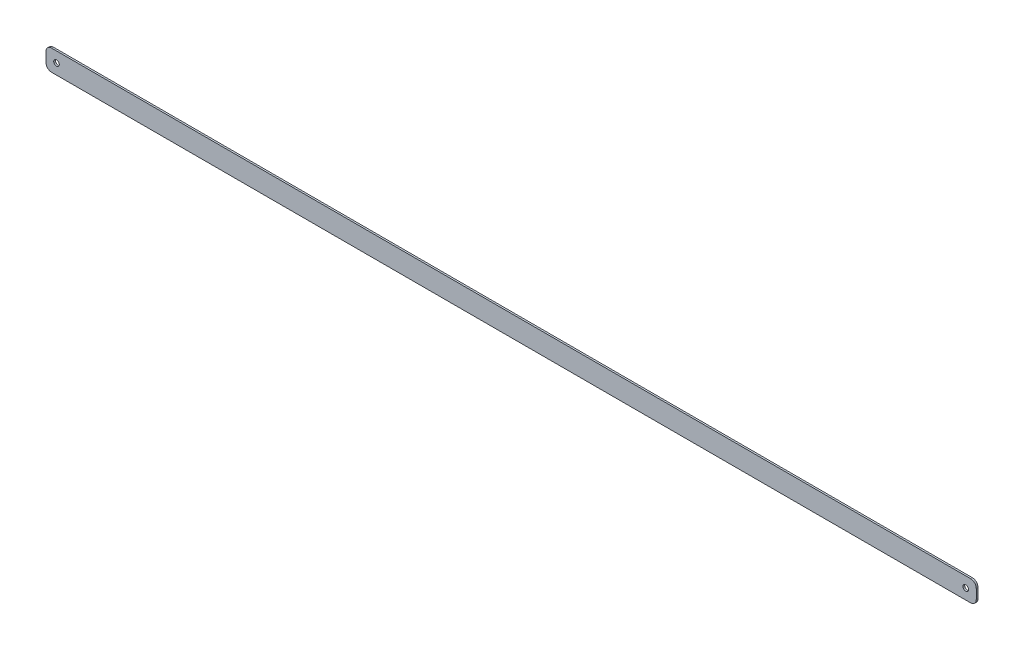
from build123d import *

# Parameters (mm, degrees)
SKETCH1_R           = 2.54
BOSS_EXTRUDE1_DEPTH = 1.5875


with BuildPart() as part:
    # Sketch1 → Boss-Extrude1 (new body)
    with BuildSketch(Plane.XY):
        with BuildLine():
            Line((-4.445, 9.525), (830.637309004, 9.525))
            ThreePointArc((830.637309004, 9.525), (834.229411452, 8.037102448), (835.717309004, 4.445))
            Line((835.717309004, 4.445), (835.717309004, -4.445))
            ThreePointArc((835.717309004, -4.445), (834.229411452, -8.037102448), (830.637309004, -9.525))
            Line((830.637309004, -9.525), (-4.445, -9.525))
            ThreePointArc((-4.445, -9.525), (-8.037102448, -8.037102448), (-9.525, -4.445))
            Line((-9.525, -4.445), (-9.525, 4.445))
            ThreePointArc((-9.525, 4.445), (-8.037102448, 8.037102448), (-4.445, 9.525))
        make_face()
        Circle(SKETCH1_R, mode=Mode.SUBTRACT)
        with Locations((826.192309004, 0)):
            Circle(SKETCH1_R, mode=Mode.SUBTRACT)
    extrude(amount=BOSS_EXTRUDE1_DEPTH)


solid = part.part
